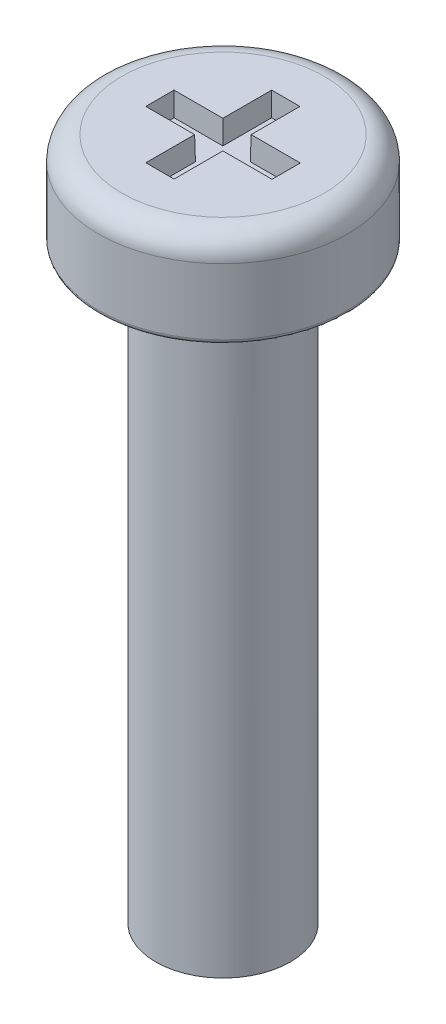
from build123d import *

# Parameters (mm, degrees)
SKETCH1_R           = 2.65
BOSS_EXTRUDE1_DEPTH = 2
SKETCH2_R           = 1.43
BOSS_EXTRUDE2_DEPTH = 12.5
FILLET1_R           = 0.5
FILLET2_R           = 0.1
CUT_EXTRUDE1_DEPTH  = 0.5
CUT_EXTRUDE1_TAPER  = 1


with BuildPart() as part:
    # Sketch1 → Boss-Extrude1 (new body)
    with BuildSketch(Plane(origin=(0, 0, 0), x_dir=(1, 0, 0), z_dir=(0, 1, 0))):
        Circle(SKETCH1_R)
    extrude(amount=BOSS_EXTRUDE1_DEPTH)

    # Sketch2 → Boss-Extrude2 (add)
    with BuildSketch(Plane.XZ):
        Circle(SKETCH2_R)
    extrude(amount=BOSS_EXTRUDE2_DEPTH)

    # Fillet1
    fillet1_edges = [part.edges().sort_by_distance(p)[0] for p in [
        (-2.65, 2, 0),
    ]]
    fillet(fillet1_edges, radius=FILLET1_R)

    # Fillet2
    fillet2_edges = [part.edges().sort_by_distance(p)[0] for p in [
        (-2.65, 0, 0),
    ]]
    fillet(fillet2_edges, radius=FILLET2_R)

    # Sketch3 → Cut-Extrude1 (cut)
    with BuildSketch(Plane(origin=(0, 2, 0), x_dir=(1, 0, 0), z_dir=(0, 1, 0))):
        Polygon((0.296573117, 0.3), (0.296573117, 1.336133674), (-0.303426883, 1.336133674), (-0.303426883, 0.3), (-1.340662941, 0.3), (-1.340662941, -0.3), (-0.303426883, -0.3), (-0.303426883, -1.336133674), (0.296573117, -1.336133674), (0.296573117, -0.3), (1.340662941, -0.3), (1.340662941, 0.3), align=None)
    extrude(amount=-CUT_EXTRUDE1_DEPTH, taper=CUT_EXTRUDE1_TAPER, mode=Mode.SUBTRACT)


solid = part.part
